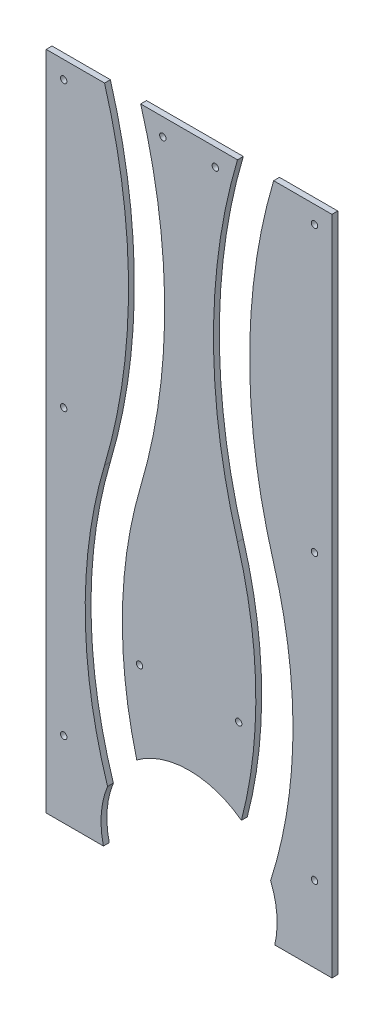
from build123d import *

# Parameters (mm, degrees)
ESQUISSE1_W                         = 245
ESQUISSE1_H                         = 517
BOSS_EXTRU_1_DEPTH                  = 5
D_GAGEMENT_M51_D                    = 5.5
BOSS_EXTRU_2_DEPTH                  = 5
ENL_V_MAT_EXTRU_4_REACH             = 7
ENL_V_MAT_EXTRU_4_DIRECTION_2_DEPTH = 1
ESQUISSE9_R                         = 75.5
ENL_V_MAT_EXTRU_5_DEPTH             = 6
ENL_V_MAT_EXTRU_7_REACH             = 7
ESQUISSE13_W                        = 5
ESQUISSE13_H                        = 17


with BuildPart() as part:
    # Esquisse1 → Boss.-Extru.1 (new body)
    with BuildSketch(Plane.XY):
        with Locations((122.5, 258.5)):
            Rectangle(ESQUISSE1_W, ESQUISSE1_H)
    extrude(amount=BOSS_EXTRU_1_DEPTH)

    # Dégagement M51 (through all)
    with Locations(Plane(origin=(15, 502, 5), x_dir=(1, 0, 0), z_dir=(0, 0, 1))):
        with Locations((0, 0), (0, -487), (0, -243.5), (85, 0), (130, 0), (65, -402), (150, -402), (215, -487), (215, -243.5), (215, 0)):
            Hole(D_GAGEMENT_M51_D / 2)

    # Esquisse5 → Boss.-Extru.2 (add)
    with BuildSketch(Plane.XY):
        Polygon((0, 0), (245, 0), (245, -50), (0, -50), (-5, -50), (-5, -33), (0, -33), align=None)
    extrude(amount=BOSS_EXTRU_2_DEPTH)

    # Esquisse7 → Enlèv. mat.-Extru.4 (cut, up to next)
    with BuildSketch(Plane.XY.offset(5), mode=Mode.PRIVATE) as enl_v_mat_extru_4_sk1:
        with BuildLine():
            Line((50, 517), (81, 517))
            ThreePointArc((81, 517), (101.568699483, 375.064704586), (81, 233.129409171))
            ThreePointArc((81, 233.129409171), (66.939640676, 89.008542991), (107.5, -50))
            Line((107.5, -50), (70.5, -50))
            ThreePointArc((70.5, -50), (34.481692227, 89.698948884), (50, 233.129409171))
            ThreePointArc((50, 233.129409171), (70.568699483, 375.064704586), (50, 517))
        make_face()
    enl_v_mat_extru_4_tool1 = extrude(enl_v_mat_extru_4_sk1.sketch, amount=-ENL_V_MAT_EXTRU_4_REACH, mode=Mode.PRIVATE) & part.part
    add(enl_v_mat_extru_4_tool1.solids().sort_by_distance((69.238426, 227.207217, 5))[0], mode=Mode.SUBTRACT)
    # Esquisse7 → Enlèv. mat.-Extru.4 (cut, up to next)
    with BuildSketch(Plane.XY.offset(5), mode=Mode.PRIVATE) as enl_v_mat_extru_4_sk2:
        with BuildLine():
            Line((164, 517), (195, 517))
            ThreePointArc((195, 517), (174.431300517, 375.064704586), (195, 233.129409171))
            ThreePointArc((195, 233.129409171), (210.518307773, 89.698948884), (174.5, -50))
            Line((174.5, -50), (137.5, -50))
            ThreePointArc((137.5, -50), (178.060359324, 89.008542991), (164, 233.129409171))
            ThreePointArc((164, 233.129409171), (143.431300517, 375.064704586), (164, 517))
        make_face()
    enl_v_mat_extru_4_tool2 = extrude(enl_v_mat_extru_4_sk2.sketch, amount=-ENL_V_MAT_EXTRU_4_REACH, mode=Mode.PRIVATE) & part.part
    add(enl_v_mat_extru_4_tool2.solids().sort_by_distance((175.761574, 227.207217, 5))[0], mode=Mode.SUBTRACT)

    # Esquisse7 → Enlèv. mat.-Extru.4 direction 2 (cut)
    with BuildSketch(Plane.XY.offset(5)):
        with BuildLine():
            Line((50, 517), (81, 517))
            ThreePointArc((81, 517), (101.568699483, 375.064704586), (81, 233.129409171))
            ThreePointArc((81, 233.129409171), (66.939640676, 89.008542991), (107.5, -50))
            Line((107.5, -50), (70.5, -50))
            ThreePointArc((70.5, -50), (34.481692227, 89.698948884), (50, 233.129409171))
            ThreePointArc((50, 233.129409171), (70.568699483, 375.064704586), (50, 517))
        make_face()
        with BuildLine():
            Line((164, 517), (195, 517))
            ThreePointArc((195, 517), (174.431300517, 375.064704586), (195, 233.129409171))
            ThreePointArc((195, 233.129409171), (210.518307773, 89.698948884), (174.5, -50))
            Line((174.5, -50), (137.5, -50))
            ThreePointArc((137.5, -50), (178.060359324, 89.008542991), (164, 233.129409171))
            ThreePointArc((164, 233.129409171), (143.431300517, 375.064704586), (164, 517))
        make_face()
    extrude(amount=ENL_V_MAT_EXTRU_4_DIRECTION_2_DEPTH, mode=Mode.SUBTRACT)

    # Esquisse9 → Enlèv. mat.-Extru.5 (cut, through all)
    with BuildSketch(Plane.XY.offset(5)):
        with Locations((122.5, -32.5)):
            Circle(ESQUISSE9_R)
    extrude(amount=-ENL_V_MAT_EXTRU_5_DEPTH, mode=Mode.SUBTRACT)

    # Esquisse13 → Enlèv. mat.-Extru.7 (cut, up to next)
    with BuildSketch(Plane(origin=(0, 0, 0), x_dir=(-1, 0, 0), z_dir=(0, 0, -1)), mode=Mode.PRIVATE) as enl_v_mat_extru_7_sk1:
        with Locations((2.5, -41.5)):
            Rectangle(ESQUISSE13_W, ESQUISSE13_H)
    enl_v_mat_extru_7_tool1 = extrude(enl_v_mat_extru_7_sk1.sketch, amount=-ENL_V_MAT_EXTRU_7_REACH, mode=Mode.PRIVATE) & part.part
    add(enl_v_mat_extru_7_tool1.solids().sort_by_distance((-2.5, -41.5, 0))[0], mode=Mode.SUBTRACT)


solid = part.part
